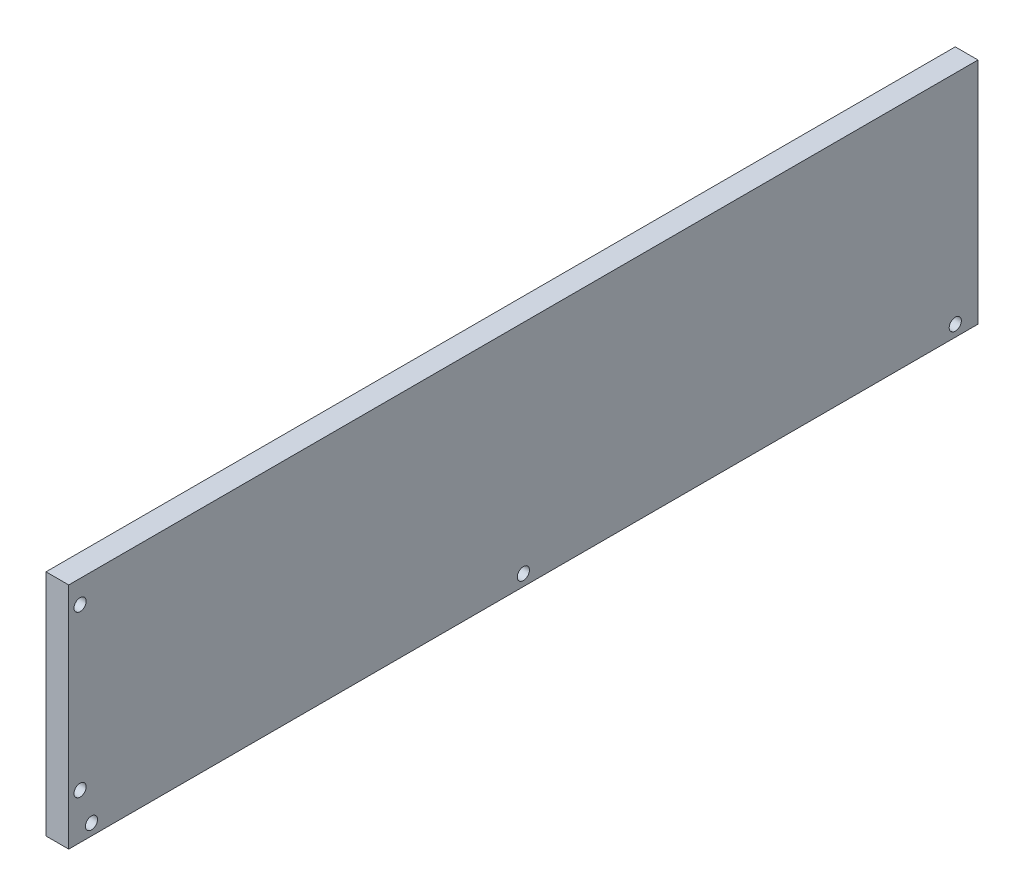
from build123d import *

# Parameters (mm, degrees)
SKETCH1_W           = 600
SKETCH1_H           = 151
BOSS_EXTRUDE1_DEPTH = 15
SKETCH2_R           = 4
CUT_EXTRUDE1_DEPTH  = 10
SKETCH2_3_R         = 4
CUT_EXTRUDE2_DEPTH  = 10
LPATTERN1_COUNT     = 3
LPATTERN1_PITCH     = 285
LPATTERN2_COUNT     = 2
LPATTERN2_PITCH     = 106
SKETCH5_R           = 4
CUT_EXTRUDE5_DEPTH  = 10
LPATTERN5_COUNT     = 2
LPATTERN5_PITCH     = 121


with BuildPart() as part:
    # Sketch1 → Boss-Extrude1 (new body)
    with BuildSketch(Plane(origin=(0, 0, 0), x_dir=(0, 0, -1), z_dir=(1, 0, 0))):
        Rectangle(SKETCH1_W, SKETCH1_H)
    extrude(amount=BOSS_EXTRUDE1_DEPTH)

    # Sketch2 → Cut-Extrude1 (cut)
    with BuildSketch(Plane(origin=(15, 0, 0), x_dir=(0, 0, -1), z_dir=(1, 0, 0))):
        with Locations((285, -68)):
            Circle(SKETCH2_R)
    cut_extrude1 = extrude(amount=-CUT_EXTRUDE1_DEPTH, mode=Mode.SUBTRACT)

    # Sketch2_3 → Cut-Extrude2 (cut)
    with BuildSketch(Plane(origin=(15, 0, 0), x_dir=(0, 0, -1), z_dir=(1, 0, 0))):
        with Locations((-292.5, 60.5)):
            Circle(SKETCH2_3_R)
    cut_extrude2 = extrude(amount=-CUT_EXTRUDE2_DEPTH, mode=Mode.SUBTRACT)

    # LPattern1: Cut-Extrude1 ×3
    with Locations(*[(0, 0, i * LPATTERN1_PITCH) for i in range(1, LPATTERN1_COUNT)]):
        add(cut_extrude1, mode=Mode.SUBTRACT)

    # LPattern2: Cut-Extrude2 ×2
    with Locations(*[(0, -i * LPATTERN2_PITCH, 0) for i in range(1, LPATTERN2_COUNT)]):
        add(cut_extrude2, mode=Mode.SUBTRACT)

    # Sketch5 → Cut-Extrude5 (cut)
    with BuildSketch(Plane(origin=(0, 0, -300), x_dir=(-1, 0, 0), z_dir=(0, 0, -1))):
        with Locations((-7.5, 60.5)):
            Circle(SKETCH5_R)
    cut_extrude5 = extrude(amount=-CUT_EXTRUDE5_DEPTH, mode=Mode.SUBTRACT)

    # LPattern5: Cut-Extrude5 ×2
    with Locations(*[(0, -i * LPATTERN5_PITCH, 0) for i in range(1, LPATTERN5_COUNT)]):
        add(cut_extrude5, mode=Mode.SUBTRACT)


solid = part.part
